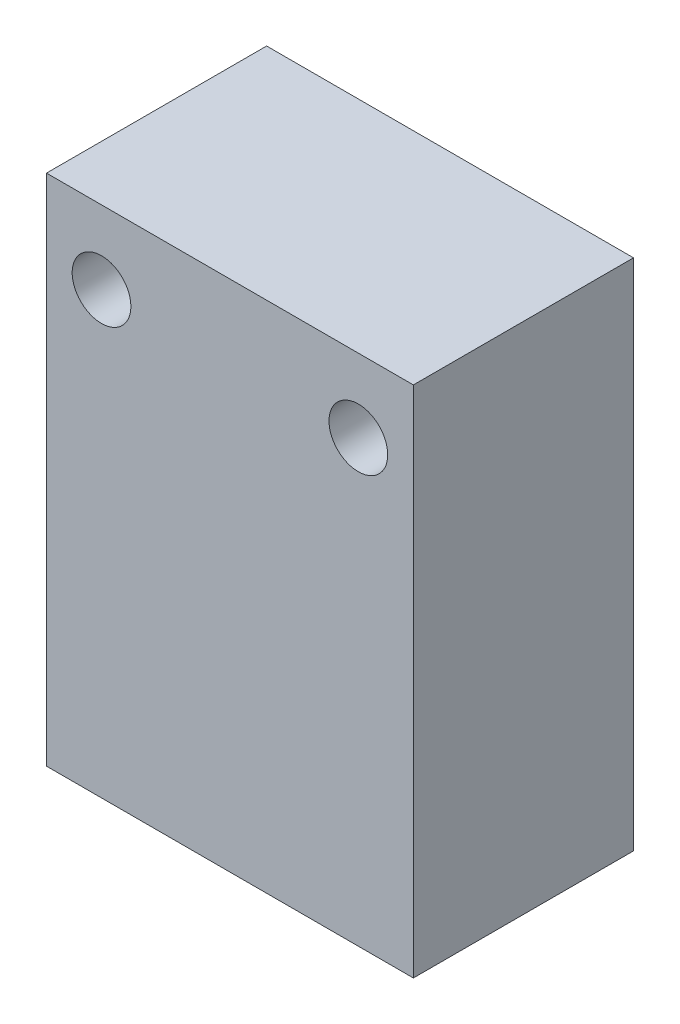
from build123d import *

# Parameters (mm, degrees)
SKETCH_1_W          = 20
SKETCH_1_H          = 28
EXTRUDE_1_DEPTH     = 12
SKETCH_2_R          = 1.6
CUT_EXTRUDE_1_DEPTH = 13


with BuildPart() as part:
    # 草图1 → 凸台-拉伸1 (new body)
    with BuildSketch(Plane.XY):
        with Locations((-2.985074627, -2.28358209)):
            Rectangle(SKETCH_1_W, SKETCH_1_H)
    extrude(amount=EXTRUDE_1_DEPTH)

    # 草图2 → 切除-拉伸1 (cut, through all)
    with BuildSketch(Plane.XY.offset(12)):
        with Locations((-9.985074627, 7.71641791)):
            Circle(SKETCH_2_R)
        with Locations((4.014925373, 7.71641791)):
            Circle(SKETCH_2_R)
    extrude(amount=-CUT_EXTRUDE_1_DEPTH, mode=Mode.SUBTRACT)


solid = part.part
